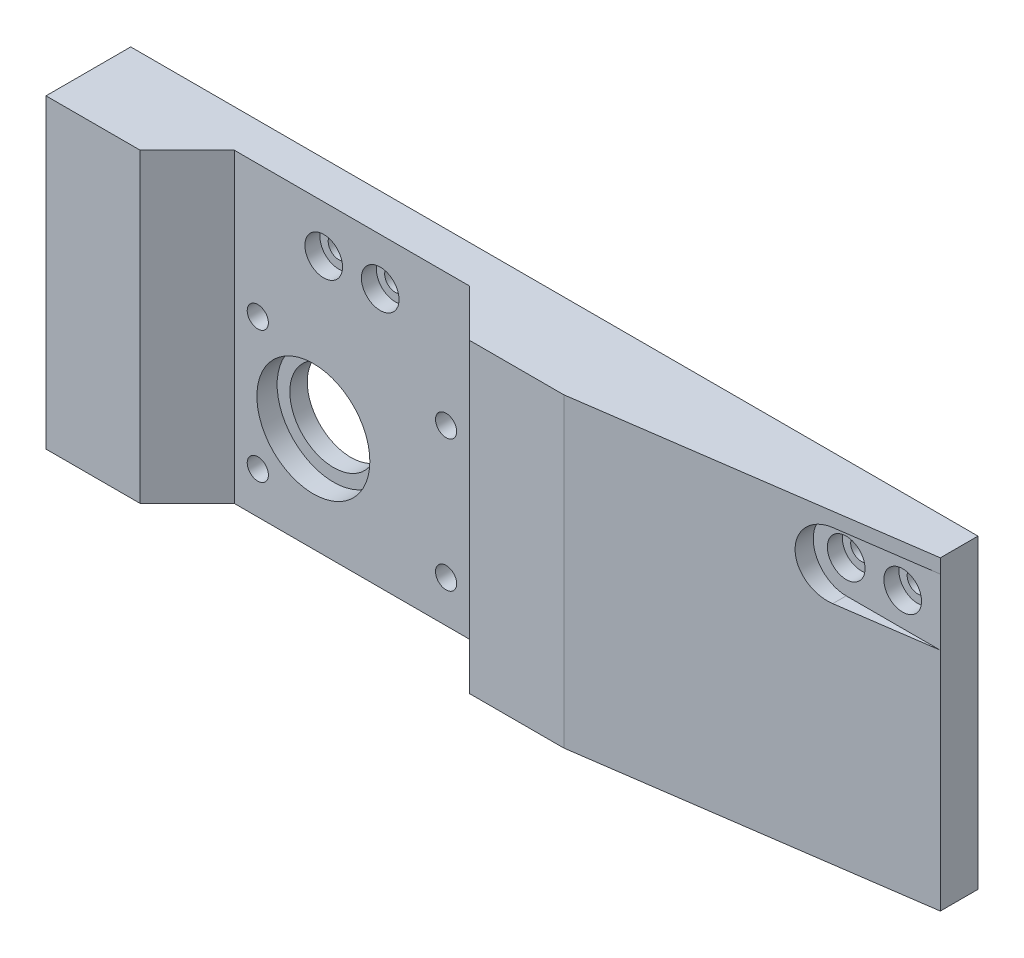
from build123d import *

# Parameters (mm, degrees)
BOSS_EXTRUDE1_DEPTH                                 = 65
F_4_0MM_DOWEL_HOLE1_D                               = 4
F_4_0MM_DOWEL_HOLE1_DEPTH                           = 7.1
F_4_0MM_DOWEL_HOLE1_TIP                             = 1.201721238
CUT_EXTRUDE1_START                                  = 8
CUT_EXTRUDE1_DEPTH                                  = 8
CBORE_FOR_M4_HEX_SOCKET_HEAD_CAP_SCREW1_D           = 4.5
CBORE_FOR_M4_HEX_SOCKET_HEAD_CAP_SCREW1_DEPTH       = 8
CBORE_FOR_M4_HEX_SOCKET_HEAD_CAP_SCREW1_CBORE_D     = 8
CBORE_FOR_M4_HEX_SOCKET_HEAD_CAP_SCREW1_CBORE_DEPTH = 3.2
SKETCH8_R                                           = 12
CUT_EXTRUDE2_DEPTH                                  = 4.3
CUT_EXTRUDE3_REACH                                  = 5.7
SKETCH9_R                                           = 9.3
M4_CLEARANCE_HOLE1_D                                = 4.5
M4_CLEARANCE_HOLE1_DEPTH                            = 8


with BuildPart() as part:
    # Sketch2 → Boss-Extrude1 (new body)
    with BuildSketch(Plane(origin=(0, 0, 0), x_dir=(1, 0, 0), z_dir=(0, 1, 0))):
        Polygon((180, 0), (0, 0), (0, -18), (20, -18), (30, -8), (80, -8), (90, -18), (110, -18), (180, -8), align=None)
    extrude(amount=BOSS_EXTRUDE1_DEPTH)

    # Ø4.0mm Dowel Hole1
    with Locations(Plane(origin=(0, 0, 0), x_dir=(-1, 0, 0), z_dir=(0, -1, 0))):
        with Locations((-5, -13), (-15, -13), (-95, -13), (-105, -13), (-22.5, -5), (-87.5, -5)):
            Hole(F_4_0MM_DOWEL_HOLE1_D / 2, depth=F_4_0MM_DOWEL_HOLE1_DEPTH)
            with Locations((0, 0, -(F_4_0MM_DOWEL_HOLE1_DEPTH + F_4_0MM_DOWEL_HOLE1_TIP / 2))):  # 118° drill point
                Cone(0, F_4_0MM_DOWEL_HOLE1_D / 2, F_4_0MM_DOWEL_HOLE1_TIP, mode=Mode.SUBTRACT)

    # Sketch5 → Cut-Extrude1 (cut)
    with BuildSketch(Plane.XY.offset(CUT_EXTRUDE1_START)):
        with BuildLine():
            Line((180, 48), (160, 48))
            ThreePointArc((160, 48), (153, 55), (160, 62))
            Line((160, 62), (180, 62))
            ThreePointArc((180, 62), (187, 55), (180, 48))
        make_face()
    extrude(amount=CUT_EXTRUDE1_DEPTH, mode=Mode.SUBTRACT)

    # CBORE for M4 Hex Socket Head Cap Screw1
    with Locations(Plane.XY.offset(8)):
        with Locations((160, 55), (172, 55), (49, 55), (61, 55)):
            CounterBoreHole(CBORE_FOR_M4_HEX_SOCKET_HEAD_CAP_SCREW1_D / 2, CBORE_FOR_M4_HEX_SOCKET_HEAD_CAP_SCREW1_CBORE_D / 2, CBORE_FOR_M4_HEX_SOCKET_HEAD_CAP_SCREW1_CBORE_DEPTH, depth=CBORE_FOR_M4_HEX_SOCKET_HEAD_CAP_SCREW1_DEPTH)

    # Sketch8 → Cut-Extrude2 (cut)
    with BuildSketch(Plane.XY.offset(8)):
        with Locations((46.8, 22.15)):
            Circle(SKETCH8_R)
    extrude(amount=-CUT_EXTRUDE2_DEPTH, mode=Mode.SUBTRACT)

    # Sketch9 → Cut-Extrude3 (cut, up to next)
    with BuildSketch(Plane.XY.offset(3.7), mode=Mode.PRIVATE) as cut_extrude3_sk1:
        with Locations((46.8, 22.15)):
            Circle(SKETCH9_R)
    cut_extrude3_tool1 = extrude(cut_extrude3_sk1.sketch, amount=-CUT_EXTRUDE3_REACH, mode=Mode.PRIVATE) & part.part
    add(cut_extrude3_tool1.solids().sort_by_distance((46.8, 22.15, 3.7))[0], mode=Mode.SUBTRACT)

    # M4 Clearance Hole1
    with Locations(Plane.XY.offset(8)):
        with Locations((35, 36.853925583), (75, 36.853925583), (75, 8.853925583), (35, 8.853925583)):
            Hole(M4_CLEARANCE_HOLE1_D / 2, depth=M4_CLEARANCE_HOLE1_DEPTH)


solid = part.part
